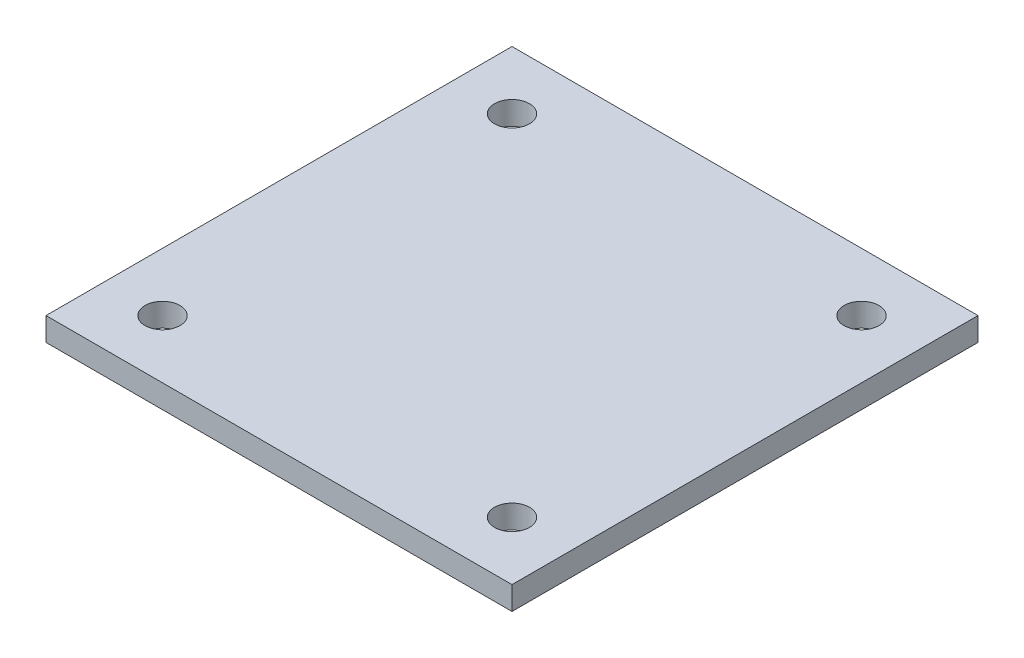
from build123d import *

# Parameters (mm, degrees)
SKETCH1_W           = 40
SKETCH1_H           = 40
BOSS_EXTRUDE1_DEPTH = 2
SKETCH2_R           = 1.5
CUT_EXTRUDE1_DEPTH  = 2


with BuildPart() as part:
    # Sketch1 → Boss-Extrude1 (new body)
    with BuildSketch(Plane(origin=(0, 0, 0), x_dir=(1, 0, 0), z_dir=(0, 1, 0))):
        with Locations((20, 20)):
            Rectangle(SKETCH1_W, SKETCH1_H)
    extrude(amount=BOSS_EXTRUDE1_DEPTH)

    # Sketch2 → Cut-Extrude1 (cut)
    with BuildSketch(Plane.XZ):
        with Locations((35, -5)):
            Circle(SKETCH2_R)
        with Locations((35, -35)):
            Circle(SKETCH2_R)
        with Locations((5, -5)):
            Circle(SKETCH2_R)
        with Locations((5, -35)):
            Circle(SKETCH2_R)
    extrude(amount=-CUT_EXTRUDE1_DEPTH, mode=Mode.SUBTRACT)


solid = part.part
